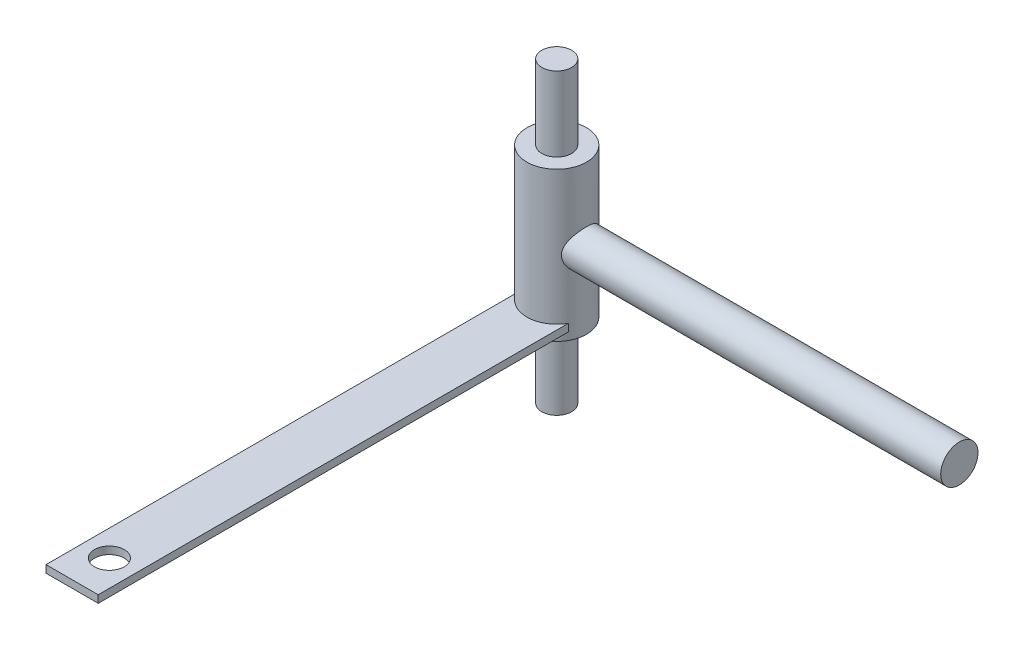
from build123d import *

# Parameters (mm, degrees)
SKETCH1_R           = 4
BOSS_EXTRUDE1_DEPTH = 40
SKETCH3_R           = 8
BOSS_EXTRUDE2_DEPTH = 20
SKETCH4_R           = 5
BOSS_EXTRUDE3_DEPTH = 108
SKETCH5_W           = 14
SKETCH5_H           = 2
BOSS_EXTRUDE4_DEPTH = 130
CUT_EXTRUDE1_REACH  = 26
SKETCH6_R           = 4


with BuildPart() as part:
    # Sketch1 → Boss-Extrude1 (new body, symmetric)
    with BuildSketch(Plane(origin=(0, 0, 0), x_dir=(1, 0, 0), z_dir=(0, 1, 0))):
        Circle(SKETCH1_R)
    extrude(amount=BOSS_EXTRUDE1_DEPTH, both=True)

    # Sketch3 → Boss-Extrude2 (add, symmetric)
    with BuildSketch(Plane(origin=(0, 0, 0), x_dir=(1, 0, 0), z_dir=(0, 1, 0))):
        Circle(SKETCH3_R)
    extrude(amount=BOSS_EXTRUDE2_DEPTH, both=True)

    # Sketch4 → Boss-Extrude3 (add)
    with BuildSketch(Plane(origin=(0, 0, 0), x_dir=(0, 0, -1), z_dir=(1, 0, 0))):
        Circle(SKETCH4_R)
    extrude(amount=BOSS_EXTRUDE3_DEPTH)

    # Sketch5 → Boss-Extrude4 (add)
    with BuildSketch(Plane.XY):
        with Locations((0, -17)):
            Rectangle(SKETCH5_W, SKETCH5_H)
    extrude(amount=BOSS_EXTRUDE4_DEPTH)

    # Sketch6 → Cut-Extrude1 (cut, up to next)
    with BuildSketch(Plane(origin=(0, -16, 0), x_dir=(1, 0, 0), z_dir=(0, 1, 0)), mode=Mode.PRIVATE) as cut_extrude1_sk1:
        with Locations((0, -120)):
            Circle(SKETCH6_R)
    cut_extrude1_tool1 = extrude(cut_extrude1_sk1.sketch, amount=-CUT_EXTRUDE1_REACH, mode=Mode.PRIVATE) & part.part
    add(cut_extrude1_tool1.solids().sort_by_distance((0, -16, 120))[0], mode=Mode.SUBTRACT)


solid = part.part
